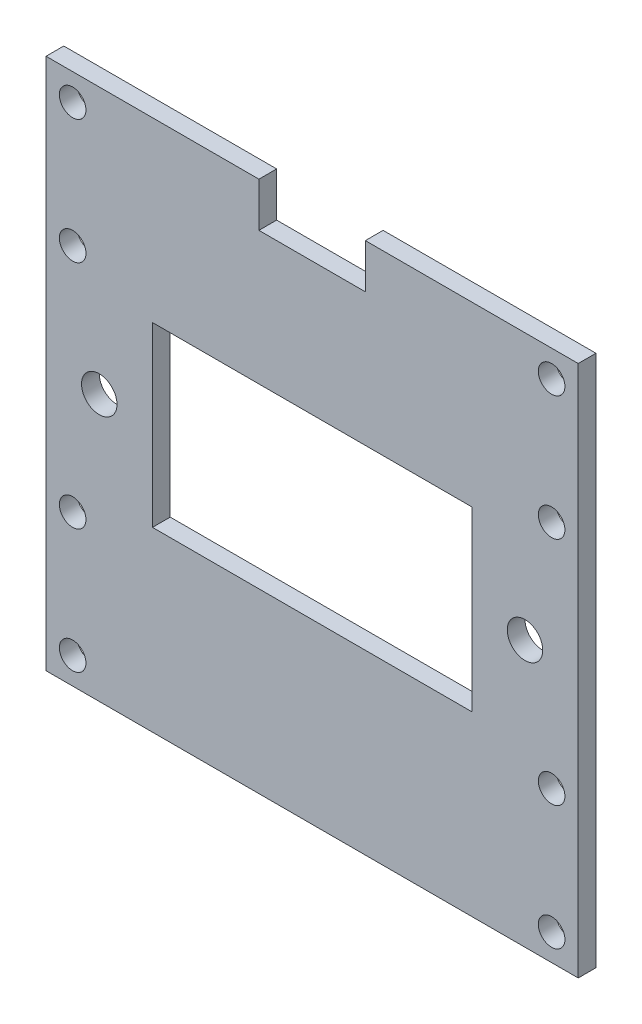
from build123d import *

# Parameters (mm, degrees)
SKETCH1_R           = 1.5
SKETCH1_R_2         = 2
SKETCH1_W           = 36
SKETCH1_H           = 20
BOSS_EXTRUDE1_DEPTH = 2


with BuildPart() as part:
    # Sketch1 → Boss-Extrude1 (new body)
    with BuildSketch(Plane.XY):
        Polygon((36, 0), (60, 0), (60, 60), (36, 60), (36, 55), (24, 55), (24, 60), (0, 60), (0, 0), (24, 0), align=None)
        with Locations((3, 57)):
            Circle(SKETCH1_R, mode=Mode.SUBTRACT)
        with Locations((3, 43)):
            Circle(SKETCH1_R, mode=Mode.SUBTRACT)
        with Locations((57, 57)):
            Circle(SKETCH1_R, mode=Mode.SUBTRACT)
        with Locations((57, 43)):
            Circle(SKETCH1_R, mode=Mode.SUBTRACT)
        with Locations((57, 17)):
            Circle(SKETCH1_R, mode=Mode.SUBTRACT)
        with Locations((57, 3)):
            Circle(SKETCH1_R, mode=Mode.SUBTRACT)
        with Locations((3, 17)):
            Circle(SKETCH1_R, mode=Mode.SUBTRACT)
        with Locations((3, 3)):
            Circle(SKETCH1_R, mode=Mode.SUBTRACT)
        with Locations((6, 30)):
            Circle(SKETCH1_R_2, mode=Mode.SUBTRACT)
        with Locations((54, 30)):
            Circle(SKETCH1_R_2, mode=Mode.SUBTRACT)
        with Locations((30, 30)):
            Rectangle(SKETCH1_W, SKETCH1_H, mode=Mode.SUBTRACT)
    extrude(amount=BOSS_EXTRUDE1_DEPTH)


solid = part.part
